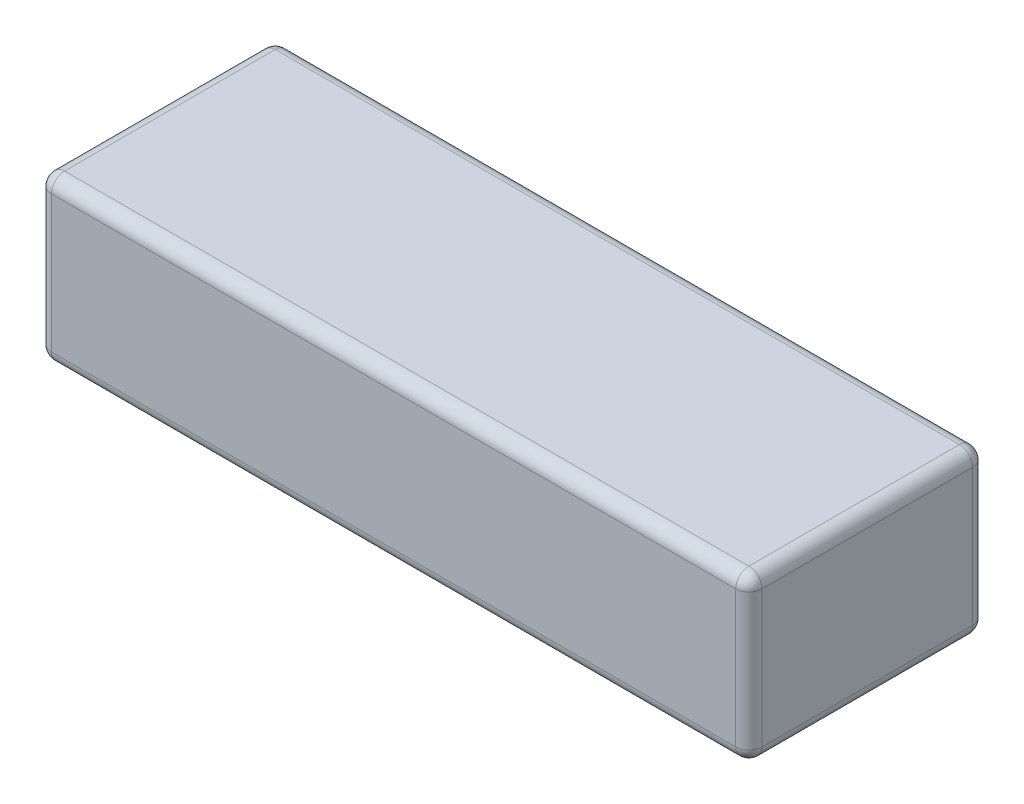
from build123d import *

# Parameters (mm, degrees)
SKETCH1_W           = 135
SKETCH1_H           = 45
BOSS_EXTRUDE1_DEPTH = 31
FILLET1_R           = 2.5


with BuildPart() as part:
    # Sketch1 → Boss-Extrude1 (new body)
    with BuildSketch(Plane(origin=(0, 0, 0), x_dir=(1, 0, 0), z_dir=(0, 1, 0))):
        Rectangle(SKETCH1_W, SKETCH1_H)
    extrude(amount=BOSS_EXTRUDE1_DEPTH)

    # Fillet1
    fillet1_edges = [part.edges().sort_by_distance(p)[0] for p in [
        (-67.5, 31, 0),
        (0, 31, 22.5),
        (67.5, 31, 0),
        (0, 0, 22.5),
        (-67.5, 0, 0),
        (0, 0, -22.5),
        (67.5, 0, 0),
        (0, 31, -22.5),
        (67.5, 15.5, 22.5),
        (-67.5, 15.5, 22.5),
        (-67.5, 15.5, -22.5),
        (67.5, 15.5, -22.5),
    ]]
    fillet(fillet1_edges, radius=FILLET1_R)


solid = part.part
